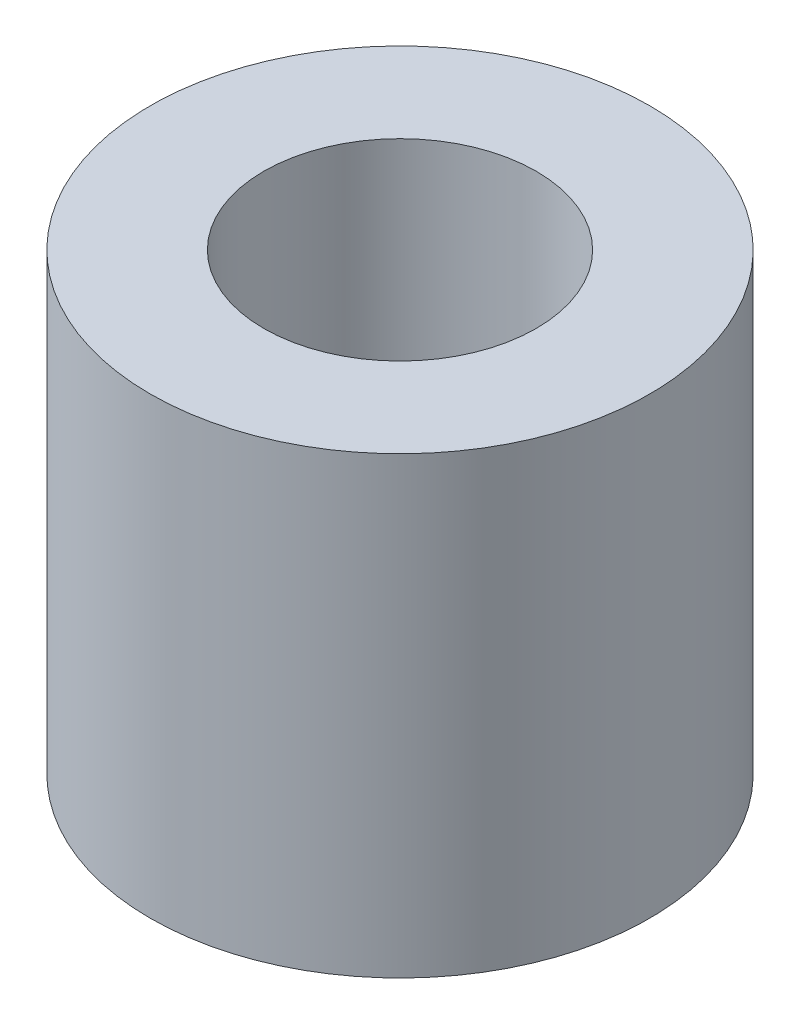
from build123d import *

# Parameters (mm, degrees)
SKETCH_1_R      = 2.75
SKETCH_1_R_2    = 1.5
EXTRUDE_1_DEPTH = 5


with BuildPart() as part:
    # Эскиз1 → Бобышка-Вытянуть1 (new body)
    with BuildSketch(Plane(origin=(0, 0, 0), x_dir=(1, 0, 0), z_dir=(0, 1, 0))):
        Circle(SKETCH_1_R)
        Circle(SKETCH_1_R_2, mode=Mode.SUBTRACT)
    extrude(amount=EXTRUDE_1_DEPTH)


solid = part.part
